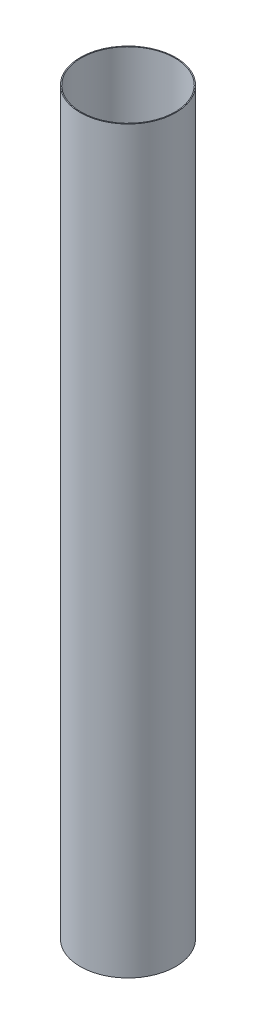
from build123d import *

# Parameters (mm, degrees)
SKETCH1_R           = 67.31
SKETCH1_R_2         = 66.04
BOSS_EXTRUDE1_DEPTH = 1041.4


with BuildPart() as part:
    # Sketch1 → Boss-Extrude1 (new body)
    with BuildSketch(Plane(origin=(0, 0, 0), x_dir=(1, 0, 0), z_dir=(0, 1, 0))):
        Circle(SKETCH1_R)
        Circle(SKETCH1_R_2, mode=Mode.SUBTRACT)
    extrude(amount=BOSS_EXTRUDE1_DEPTH)


solid = part.part
